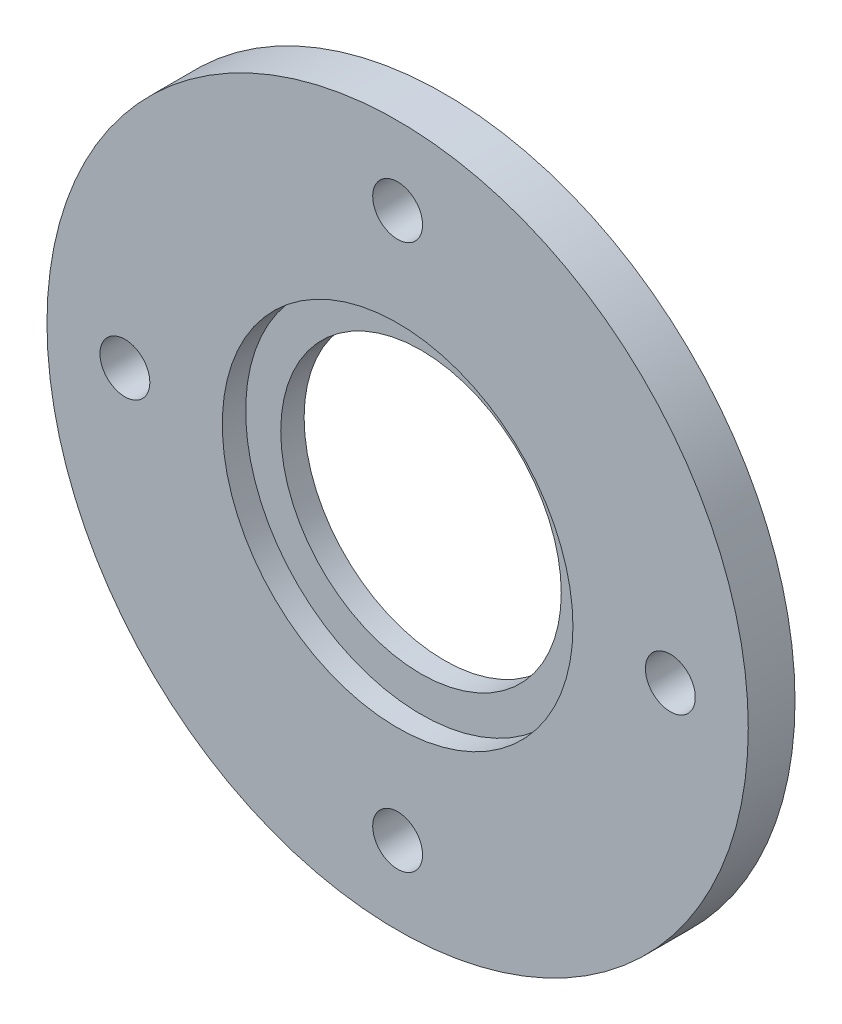
from build123d import *

# Parameters (mm, degrees)
SKETCH_1_R               = 22.5
SKETCH_1_R_2             = 9
EXTRUDE_1_DEPTH          = 3
SKETCH_2_R               = 1.6
CUT_EXTRUDE_1_DEPTH      = 4
PATTERN_CIRCULAR_2_COUNT = 4
SKETCH_3_R               = 11.25
SKETCH_3_R_2             = 9
CUT_EXTRUDE_2_DEPTH      = 1.5


with BuildPart() as part:
    # ｽｹｯﾁ1 → ﾎﾞｽ - 押し出し1 (new body)
    with BuildSketch(Plane.XY):
        Circle(SKETCH_1_R)
        Circle(SKETCH_1_R_2, mode=Mode.SUBTRACT)
    extrude(amount=EXTRUDE_1_DEPTH)

    # ｽｹｯﾁ2 → ｶｯﾄ - 押し出し1 (cut, through all)
    with BuildSketch(Plane.XY.offset(3)):
        with Locations((-17.5, 0)):
            Circle(SKETCH_2_R)
    cut_extrude_1 = extrude(amount=-CUT_EXTRUDE_1_DEPTH, mode=Mode.SUBTRACT)

    # 円形ﾊﾟﾀｰﾝ2: ｶｯﾄ - 押し出し1 ×4 about axis
    pattern_circular_2_axis = Axis((0, 0, 0), (0, 0, 1))
    for i in range(1, PATTERN_CIRCULAR_2_COUNT):
        add(cut_extrude_1.rotate(pattern_circular_2_axis, i * 360 / PATTERN_CIRCULAR_2_COUNT), mode=Mode.SUBTRACT)

    # ｽｹｯﾁ3 → ｶｯﾄ - 押し出し2 (cut)
    with BuildSketch(Plane.XY.offset(3)):
        Circle(SKETCH_3_R)
        Circle(SKETCH_3_R_2, mode=Mode.SUBTRACT)
    extrude(amount=-CUT_EXTRUDE_2_DEPTH, mode=Mode.SUBTRACT)


solid = part.part
